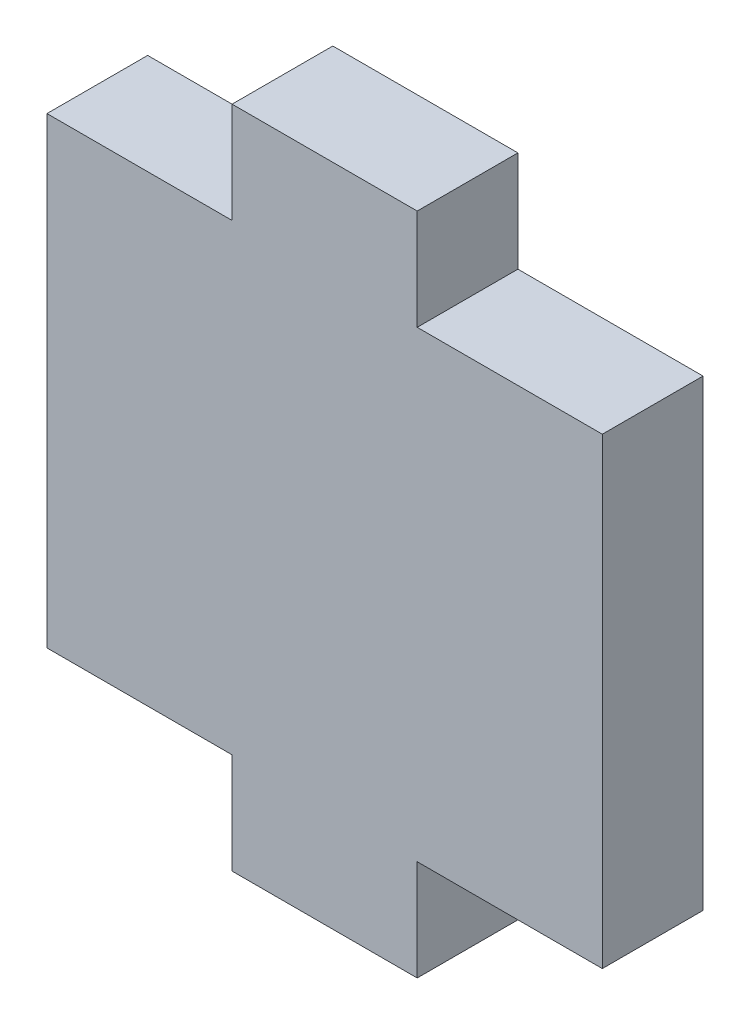
from build123d import *

# Parameters (mm, degrees)
BOSS_EXTRUDE1_DEPTH = 5.44


with BuildPart() as part:
    # Sketch1 → Boss-Extrude1 (new body)
    with BuildSketch(Plane.XY):
        Polygon((20, 0), (30, 0), (30, 25), (20, 25), (20, 30.44), (10, 30.44), (10, 25), (0, 25), (0, 0), (10, 0), (10, -5.44), (20, -5.44), align=None)
    extrude(amount=BOSS_EXTRUDE1_DEPTH)


solid = part.part
